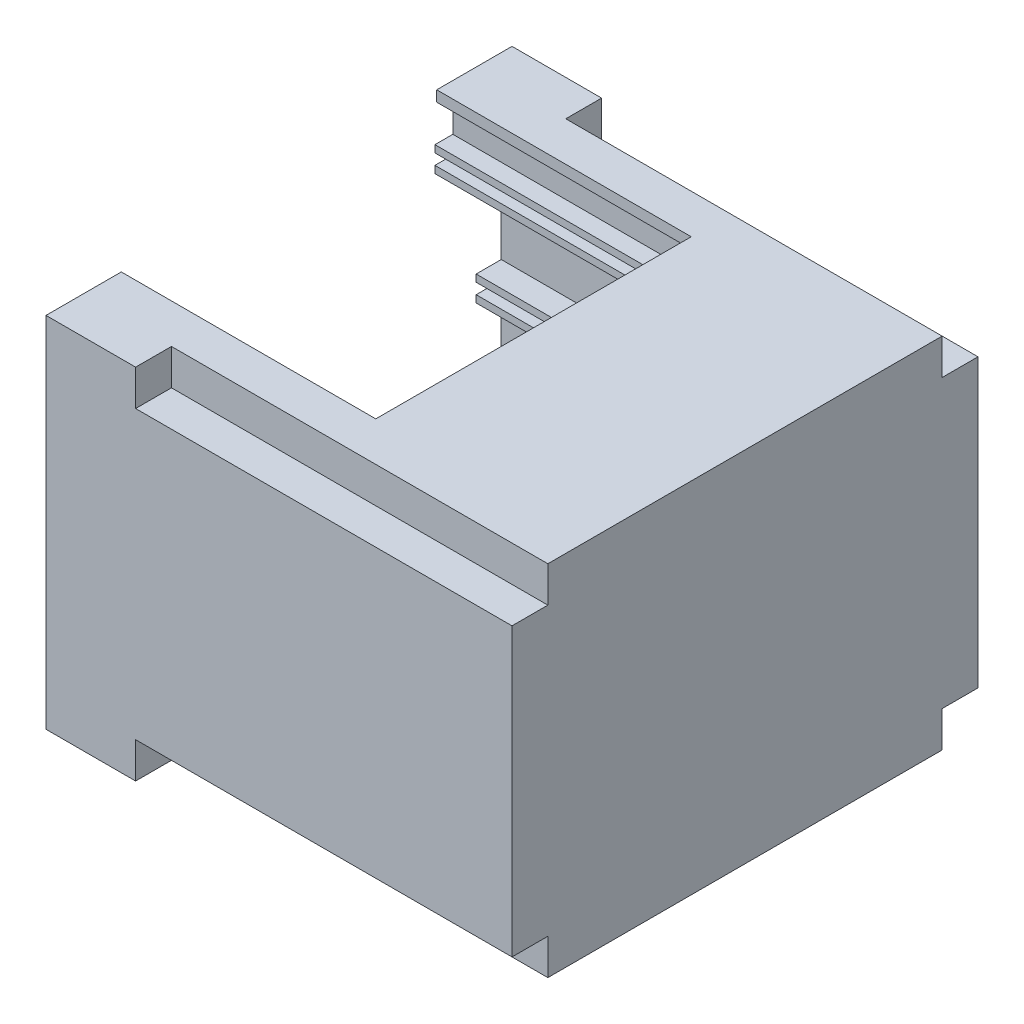
from build123d import *

# Parameters (mm, degrees)
SKETCH2_W            = 130
SKETCH2_H            = 130
BOSS_EXTRUDE1_DEPTH  = 100
SKETCH3_W            = 104
SKETCH3_H            = 74
CUT_EXTRUDE1_DEPTH   = 127
SKETCH4_W            = 10
SKETCH4_H            = 10
CUT_EXTRUDE3_DEPTH   = 105
SKETCH5_W            = 104
SKETCH5_H            = 10
CUT_EXTRUDE4_DEPTH   = 127
SKETCH6_W            = 10
SKETCH6_H            = 74
CUT_EXTRUDE5_DEPTH   = 127
SKETCH7_R            = 1.75
CUT_EXTRUDE6_DEPTH   = 20
SKETCH8_W            = 3
SKETCH8_H            = 3
CUT_EXTRUDE7_DEPTH   = 5
SKETCH9_W            = 85
SKETCH9_H            = 60
BOSS_EXTRUDE2_DEPTH  = 15
SKETCH11_W           = 85
SKETCH11_H           = 6
BOSS_EXTRUDE5_DEPTH  = 5
SKETCH12_W           = 85
SKETCH12_H           = 3
CUT_EXTRUDE9_DEPTH   = 4
SKETCH13_W           = 82
SKETCH13_H           = 57
CUT_EXTRUDE10_DEPTH  = 15
SKETCH15_W           = 3
SKETCH15_H           = 3
BOSS_EXTRUDE7_DEPTH  = 5
SKETCH16_W           = 82
SKETCH16_H           = 2
BOSS_EXTRUDE8_DEPTH  = 57
SKETCH17_W           = 77
SKETCH17_H           = 47
CUT_EXTRUDE11_DEPTH  = 10
SKETCH19_W           = 7
SKETCH19_H           = 2
SKETCH19_H_2         = 1
BOSS_EXTRUDE9_DEPTH  = 1
SKETCH21_W           = 3
SKETCH21_H           = 3
CUT_EXTRUDE15_DEPTH  = 5
SKETCH22_W           = 124
SKETCH22_H           = 7
BOSS_EXTRUDE10_DEPTH = 127
SKETCH23_W           = 120
SKETCH23_H           = 3
CUT_EXTRUDE16_DEPTH  = 125
SKETCH24_W           = 120
SKETCH24_H           = 110
CUT_EXTRUDE17_DEPTH  = 15
SKETCH25_W           = 71
SKETCH25_H           = 88
CUT_EXTRUDE18_DEPTH  = 15
SKETCH27_W           = 103
SKETCH27_H           = 17
BOSS_EXTRUDE11_DEPTH = 127
SKETCH28_W           = 97
SKETCH28_H           = 3
SKETCH28_H_2         = 10
CUT_EXTRUDE19_DEPTH  = 120
SKETCH29_W           = 4
SKETCH29_H           = 103
CUT_EXTRUDE20_DEPTH  = 17
SKETCH30_W           = 115
SKETCH30_H           = 87
CUT_EXTRUDE21_DEPTH  = 17


with BuildPart() as part:
    # Sketch2 → Boss-Extrude1 (new body)
    with BuildSketch(Plane(origin=(0, 0, 0), x_dir=(1, 0, 0), z_dir=(0, 1, 0))):
        with Locations((65, 65)):
            Rectangle(SKETCH2_W, SKETCH2_H)
    extrude(amount=BOSS_EXTRUDE1_DEPTH)

    # Sketch3 → Cut-Extrude1 (cut)
    with BuildSketch(Plane.ZY):
        with Locations((-65, 50)):
            Rectangle(SKETCH3_W, SKETCH3_H)
    extrude(amount=-CUT_EXTRUDE1_DEPTH, mode=Mode.SUBTRACT)

    # Sketch4 → Cut-Extrude3 (cut)
    with BuildSketch(Plane(origin=(130, 0, 0), x_dir=(0, 0, -1), z_dir=(1, 0, 0))):
        with Locations((5, 95)):
            Rectangle(SKETCH4_W, SKETCH4_H)
        with Locations((125, 95)):
            Rectangle(SKETCH4_W, SKETCH4_H)
        with Locations((5, 5)):
            Rectangle(SKETCH4_W, SKETCH4_H)
        with Locations((125, 5)):
            Rectangle(SKETCH4_W, SKETCH4_H)
    extrude(amount=-CUT_EXTRUDE3_DEPTH, mode=Mode.SUBTRACT)

    # Sketch5 → Cut-Extrude4 (cut)
    with BuildSketch(Plane.ZY):
        with Locations((-65, 92)):
            Rectangle(SKETCH5_W, SKETCH5_H)
        with Locations((-65, 8)):
            Rectangle(SKETCH5_W, SKETCH5_H)
    extrude(amount=-CUT_EXTRUDE4_DEPTH, mode=Mode.SUBTRACT)

    # Sketch6 → Cut-Extrude5 (cut)
    with BuildSketch(Plane.ZY):
        with Locations((-122, 50)):
            Rectangle(SKETCH6_W, SKETCH6_H)
        with Locations((-8, 50)):
            Rectangle(SKETCH6_W, SKETCH6_H)
    extrude(amount=-CUT_EXTRUDE5_DEPTH, mode=Mode.SUBTRACT)

    # Sketch7 → Cut-Extrude6 (cut)
    with BuildSketch(Plane.ZY):
        with Locations((-124, 94)):
            Circle(SKETCH7_R)
        with Locations((-6, 94)):
            Circle(SKETCH7_R)
        with Locations((-124, 6)):
            Circle(SKETCH7_R)
        with Locations((-6, 6)):
            Circle(SKETCH7_R)
    extrude(amount=-CUT_EXTRUDE6_DEPTH, mode=Mode.SUBTRACT)

    # Sketch8 → Cut-Extrude7 (cut)
    with BuildSketch(Plane.ZY):
        with Locations((-118.5, 88.5)):
            Rectangle(SKETCH8_W, SKETCH8_H)
        with Locations((-11.5, 88.5)):
            Rectangle(SKETCH8_W, SKETCH8_H)
        with Locations((-118.5, 11.5)):
            Rectangle(SKETCH8_W, SKETCH8_H)
        with Locations((-11.5, 11.5)):
            Rectangle(SKETCH8_W, SKETCH8_H)
    extrude(amount=-CUT_EXTRUDE7_DEPTH, mode=Mode.SUBTRACT)

    # Sketch9 → Boss-Extrude2 (add)
    with BuildSketch(Plane(origin=(0, 3, 0), x_dir=(1, 0, 0), z_dir=(0, 1, 0))):
        with Locations((42.5, 87)):
            Rectangle(SKETCH9_W, SKETCH9_H)
    extrude(amount=BOSS_EXTRUDE2_DEPTH)

    # Sketch11 → Boss-Extrude5 (add)
    with BuildSketch(Plane(origin=(0, 13, 0), x_dir=(1, 0, 0), z_dir=(0, 1, 0))):
        with Locations((42.5, 120)):
            Rectangle(SKETCH11_W, SKETCH11_H)
    extrude(amount=BOSS_EXTRUDE5_DEPTH)

    # Sketch12 → Cut-Extrude9 (cut)
    with BuildSketch(Plane(origin=(0, 18, 0), x_dir=(1, 0, 0), z_dir=(0, 1, 0))):
        with Locations((42.5, 121.5)):
            Rectangle(SKETCH12_W, SKETCH12_H)
    extrude(amount=-CUT_EXTRUDE9_DEPTH, mode=Mode.SUBTRACT)

    # Sketch13 → Cut-Extrude10 (cut)
    with BuildSketch(Plane(origin=(0, 18, 0), x_dir=(1, 0, 0), z_dir=(0, 1, 0))):
        with Locations((41, 88.5)):
            Rectangle(SKETCH13_W, SKETCH13_H)
    extrude(amount=-CUT_EXTRUDE10_DEPTH, mode=Mode.SUBTRACT)

    # Sketch15 → Boss-Extrude7 (add)
    with BuildSketch(Plane.ZY.offset(-5)):
        with Locations((-118.5, 11.5)):
            Rectangle(SKETCH15_W, SKETCH15_H)
    extrude(amount=BOSS_EXTRUDE7_DEPTH)

    # Sketch16 → Boss-Extrude8 (add)
    with BuildSketch(Plane(origin=(0, 0, -60), x_dir=(-1, 0, 0), z_dir=(0, 0, -1))):
        with Locations((-41, 17)):
            Rectangle(SKETCH16_W, SKETCH16_H)
        with Locations((-41, 12)):
            Rectangle(SKETCH16_W, SKETCH16_H)
    extrude(amount=BOSS_EXTRUDE8_DEPTH)

    # Sketch17 → Cut-Extrude11 (cut)
    with BuildSketch(Plane(origin=(0, 18, 0), x_dir=(1, 0, 0), z_dir=(0, 1, 0))):
        with Locations((38.5, 88.5)):
            Rectangle(SKETCH17_W, SKETCH17_H)
    extrude(amount=-CUT_EXTRUDE11_DEPTH, mode=Mode.SUBTRACT)

    # Sketch19 → Boss-Extrude9 (add)
    with BuildSketch(Plane.XY.offset(-117)):
        with Locations((3.5, 10)):
            Rectangle(SKETCH19_W, SKETCH19_H)
        with Locations((3.5, 13.5)):
            Rectangle(SKETCH19_W, SKETCH19_H_2)
    extrude(amount=BOSS_EXTRUDE9_DEPTH)

    # Sketch21 → Cut-Extrude15 (cut)
    with BuildSketch(Plane.ZY):
        with Locations((-118.5, 11.5)):
            Rectangle(SKETCH21_W, SKETCH21_H)
    extrude(amount=-CUT_EXTRUDE15_DEPTH, mode=Mode.SUBTRACT)

    # Sketch22 → Boss-Extrude10 (add)
    with BuildSketch(Plane.ZY.offset(-127)):
        with Locations((-65, 46.5)):
            Rectangle(SKETCH22_W, SKETCH22_H)
    extrude(amount=BOSS_EXTRUDE10_DEPTH)

    # Sketch23 → Cut-Extrude16 (cut)
    with BuildSketch(Plane.ZY):
        with Locations((-65, 46.5)):
            Rectangle(SKETCH23_W, SKETCH23_H)
    extrude(amount=-CUT_EXTRUDE16_DEPTH, mode=Mode.SUBTRACT)

    # Sketch24 → Cut-Extrude17 (cut)
    with BuildSketch(Plane(origin=(0, 50, 0), x_dir=(1, 0, 0), z_dir=(0, 1, 0))):
        with Locations((60, 65)):
            Rectangle(SKETCH24_W, SKETCH24_H)
    extrude(amount=-CUT_EXTRUDE17_DEPTH, mode=Mode.SUBTRACT)

    # Sketch25 → Cut-Extrude18 (cut)
    with BuildSketch(Plane(origin=(0, 100, 0), x_dir=(1, 0, 0), z_dir=(0, 1, 0))):
        with Locations((35.5, 65)):
            Rectangle(SKETCH25_W, SKETCH25_H)
    extrude(amount=-CUT_EXTRUDE18_DEPTH, mode=Mode.SUBTRACT)

    # Sketch27 → Boss-Extrude11 (add)
    with BuildSketch(Plane.ZY.offset(-127)):
        with Locations((-65, 88.5)):
            Rectangle(SKETCH27_W, SKETCH27_H)
    extrude(amount=BOSS_EXTRUDE11_DEPTH)

    # Sketch28 → Cut-Extrude19 (cut)
    with BuildSketch(Plane.ZY):
        with Locations((-65, 83.5)):
            Rectangle(SKETCH28_W, SKETCH28_H)
        with Locations((-65, 92)):
            Rectangle(SKETCH28_W, SKETCH28_H_2)
    extrude(amount=-CUT_EXTRUDE19_DEPTH, mode=Mode.SUBTRACT)

    # Sketch29 → Cut-Extrude20 (cut)
    with BuildSketch(Plane.XZ.offset(-80)):
        with Locations((125, -65)):
            Rectangle(SKETCH29_W, SKETCH29_H)
    extrude(amount=-CUT_EXTRUDE20_DEPTH, mode=Mode.SUBTRACT)

    # Sketch30 → Cut-Extrude21 (cut)
    with BuildSketch(Plane(origin=(0, 87, 0), x_dir=(1, 0, 0), z_dir=(0, 1, 0))):
        with Locations((57.5, 65)):
            Rectangle(SKETCH30_W, SKETCH30_H)
    extrude(amount=-CUT_EXTRUDE21_DEPTH, mode=Mode.SUBTRACT)


solid = part.part
